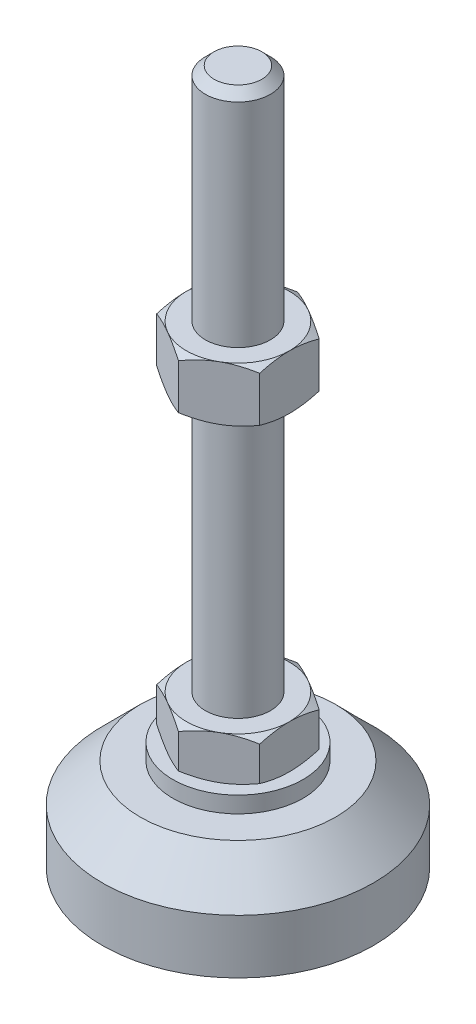
from build123d import *

# Parameters (mm, degrees)
EXTRUDE_1_DEPTH = 8
EXTRUDE_2_DEPTH = 10


with BuildPart() as part:
    # Эскиз1 → Повернуть1 (revolve)
    with BuildSketch(Plane.XY, mode=Mode.PRIVATE) as revolve_1_sk:
        Polygon((0, 0), (-25, 0), (-25, 10), (-18, 17), (-12, 17), (-12, 20), (-6, 20), (-6, 28), (-6, 126.4), (-4.4, 128), (0, 128), align=None)
    revolve(revolve_1_sk.sketch.rotate(Axis((0, 0, 0), (0, 1, 0)), 180), axis=Axis((0, 0, 0), (0, 1, 0)))  # turned: the seam where the file's is

    # Эскиз2 → Бобышка-Вытянуть1 (add)
    with BuildSketch(Plane(origin=(0, 20, 0), x_dir=(1, 0, 0), z_dir=(0, 1, 0))):
        Polygon((0, 10.969655115), (-9.5, 5.484827557), (-9.5, -5.484827557), (0, -10.969655115), (9.5, -5.484827557), (9.5, 5.484827557), align=None)
    extrude(amount=EXTRUDE_1_DEPTH)

    # Эскиз3 → Бобышка-Вытянуть2 (add)
    with BuildSketch(Plane(origin=(0, 77.2, 0), x_dir=(1, 0, 0), z_dir=(0, 1, 0))):
        Polygon((9.5, 5.484827557), (0, 10.969655115), (-9.5, 5.484827557), (-9.5, -5.484827557), (0, -10.969655115), (9.5, -5.484827557), align=None)
    extrude(amount=EXTRUDE_2_DEPTH)

    # Эскиз4 → Вырез-Повернуть2 (revolve, cut)
    with BuildSketch(Plane.XY, mode=Mode.PRIVATE) as cut_revolve_2_sk:
        Polygon((-18.160254038, 87.2), (-9.5, 87.2), (-18.160254038, 82.2), align=None)
        Polygon((-18.160254038, 77.2), (-18.160254038, 82.2), (-9.5, 77.2), align=None)
        Polygon((-16.42820323, 28), (-16.42820323, 24), (-9.5, 28), align=None)
        Polygon((-16.42820323, 24), (-16.42820323, 20), (-9.5, 20), align=None)
    revolve(cut_revolve_2_sk.sketch.rotate(Axis((0, 128, 0), (0, -1, 0)), 180), axis=Axis((0, 128, 0), (0, -1, 0)), mode=Mode.SUBTRACT)  # turned: the seam where the file's is


solid = part.part
